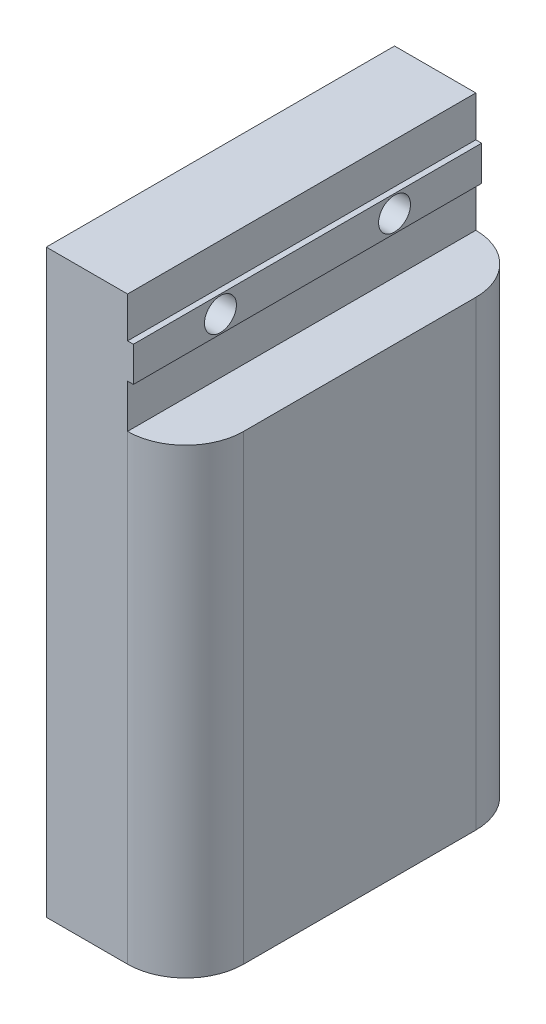
from build123d import *

# Parameters (mm, degrees)
SALIENTE_EXTRUIR1_DEPTH = 60
CROQUIS4_W              = 60
CROQUIS4_H              = 6
SALIENTE_EXTRUIR3_DEPTH = 1
CROQUIS5_R              = 2.75
CORTAR_EXTRUIR1_DEPTH   = 25
CROQUIS6_R              = 6
CORTAR_EXTRUIR2_DEPTH   = 8
REDONDEO1_R             = 10


with BuildPart() as part:
    # Croquis1 → Saliente-Extruir1 (new body)
    with BuildSketch(Plane.XY):
        Polygon((24, -100), (24, -20.5), (14, -20.5), (14, 0), (0, 0), (0, -100), align=None)
    extrude(amount=SALIENTE_EXTRUIR1_DEPTH)

    # Croquis4 → Saliente-Extruir3 (add)
    with BuildSketch(Plane(origin=(14, 0, 0), x_dir=(0, 0, -1), z_dir=(1, 0, 0))):
        with Locations((-30, -10)):
            Rectangle(CROQUIS4_W, CROQUIS4_H)
    extrude(amount=SALIENTE_EXTRUIR3_DEPTH)

    # Croquis5 → Cortar-Extruir1 (cut, through all)
    with BuildSketch(Plane.ZY):
        with Locations((15, -10)):
            Circle(CROQUIS5_R)
        with Locations((45, -10)):
            Circle(CROQUIS5_R)
    extrude(amount=-CORTAR_EXTRUIR1_DEPTH, mode=Mode.SUBTRACT)

    # Croquis6 → Cortar-Extruir2 (cut)
    with BuildSketch(Plane.ZY):
        with Locations((15, -10)):
            Circle(CROQUIS6_R)
        with Locations((45, -10)):
            Circle(CROQUIS6_R)
    extrude(amount=-CORTAR_EXTRUIR2_DEPTH, mode=Mode.SUBTRACT)

    # Redondeo1
    redondeo1_edges = [part.edges().sort_by_distance(p)[0] for p in [
        (24, -60.25, 0),
        (24, -60.25, 60),
    ]]
    fillet(redondeo1_edges, radius=REDONDEO1_R)


solid = part.part
